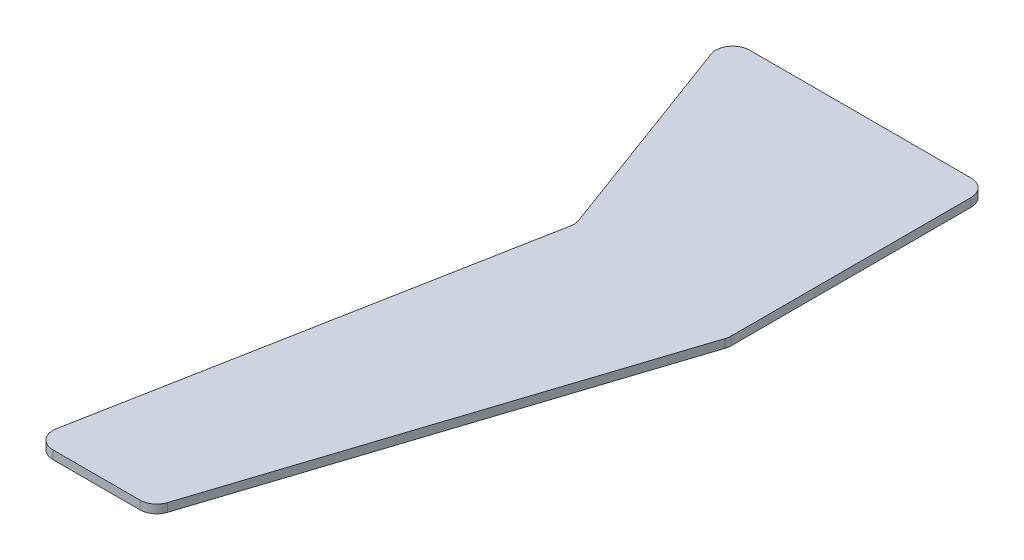
from build123d import *

# Parameters (mm, degrees)
BOSS_EXTRUDE1_DEPTH = 2


with BuildPart() as part:
    # Sketch1 → Boss-Extrude1 (new body)
    with BuildSketch(Plane(origin=(0, 0, 0), x_dir=(1, 0, 0), z_dir=(0, 1, 0))):
        with BuildLine():
            Line((-37.696644009, -112.166307969), (-18.469733274, -10.019929084))
            ThreePointArc((-18.469733274, -10.019929084), (-18.414906345, -8.943208399), (-18.649630885, -7.890954715))
            Line((-18.649630885, -7.890954715), (-37.002018096, 41.668821421))
            ThreePointArc((-37.002018096, 41.668821421), (-36.533949303, 45.343020278), (-33.250947, 47.057873482))
            Line((-33.250947, 47.057873482), (19.002372201, 47.057873482))
            ThreePointArc((19.002372201, 47.057873482), (21.830799325, 45.886300607), (23.002372201, 43.057873482))
            Line((23.002372201, 43.057873482), (23.002372201, -13.558588756))
            ThreePointArc((23.002372201, -13.558588756), (22.953125563, -14.184326617), (22.806598266, -14.794656734))
            Line((22.806598266, -14.794656734), (-9.473407239, -114.142298255))
            ThreePointArc((-9.473407239, -114.142298255), (-10.926492295, -116.142298255), (-13.277633304, -116.906230278))
            Line((-13.277633304, -116.906230278), (-33.765675302, -116.906230278))
            ThreePointArc((-33.765675302, -116.906230278), (-36.844610932, -115.459689771), (-37.696644009, -112.166307969))
        make_face()
    extrude(amount=BOSS_EXTRUDE1_DEPTH)


solid = part.part
